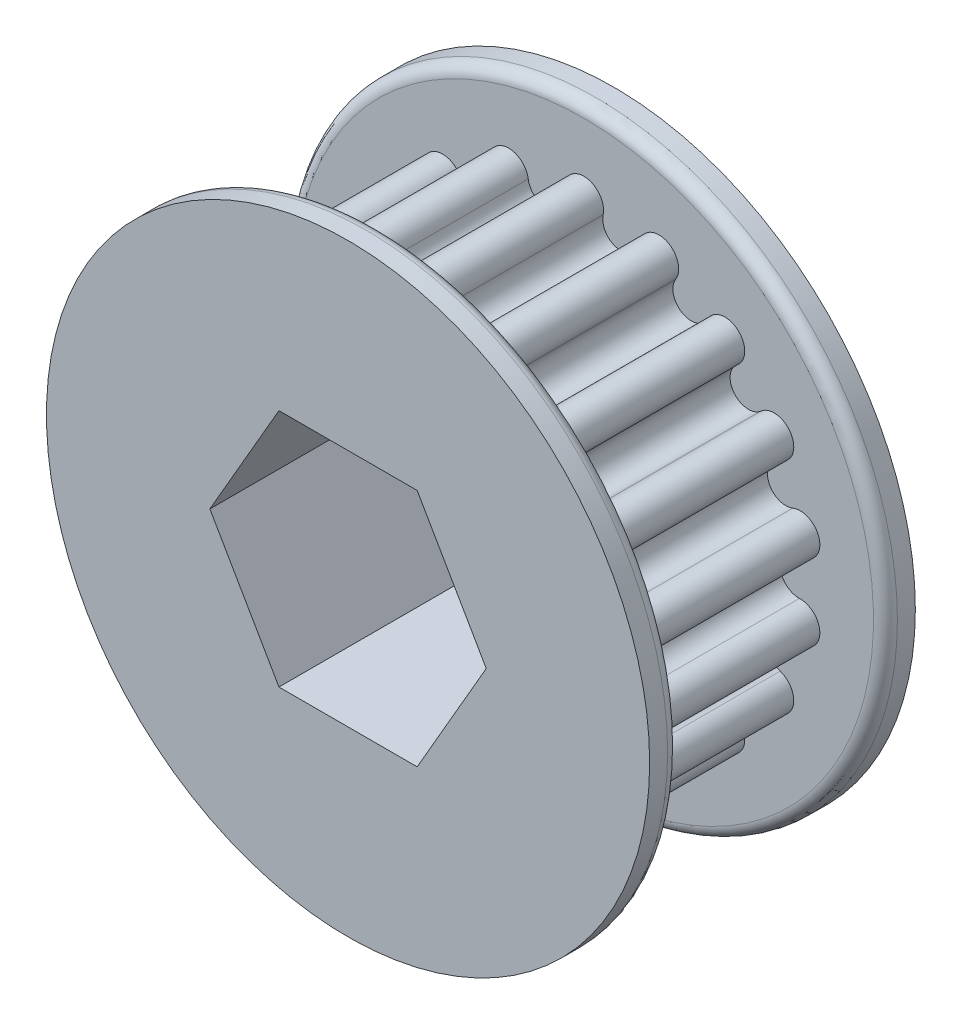
from build123d import *

# Parameters (mm, degrees)
BOSS_EXTRUDE1_DEPTH  = 10.922
SKETCH2_R            = 16.002
BOSS_EXTRUDE2_DEPTH  = 1.5875
FILLET1_R            = 0.635
FILLET1_OF_MIRROR1_R = 0.635


with BuildPart() as part:
    # Sketch1 → Boss-Extrude1 (new body)
    with BuildSketch(Plane.XY):
        with BuildLine():
            ThreePointArc((1.023014865, 11.438350063), (0, 12.7), (-1.023014865, 11.438350063))
            ThreePointArc((-1.023014865, 11.438350063), (-1.811146799, 10.271523911), (-2.950826609, 11.098424839))
            ThreePointArc((-2.950826609, 11.098424839), (-4.34365582, 11.934096284), (-4.873465647, 10.398641458))
            ThreePointArc((-4.873465647, 10.398641458), (-5.214989362, 9.032626536), (-6.568754843, 9.419865784))
            ThreePointArc((-6.568754843, 9.419865784), (-8.163402643, 9.728764428), (-8.136104548, 8.104703225))
            ThreePointArc((-8.136104548, 8.104703225), (-7.989827243, 6.704261093), (-9.3943943, 6.605131893))
            ThreePointArc((-9.3943943, 6.605131893), (-10.998522628, 6.35), (-10.417409164, 4.83321817))
            ThreePointArc((-10.417409164, 4.83321817), (-9.800974042, 3.567262818), (-11.086931157, 2.993721614))
            ThreePointArc((-11.086931157, 2.993721614), (-12.507058463, 2.205331856), (-11.442220491, 0.978775674))
            ThreePointArc((-11.442220491, 0.978775674), (-10.429978724, 0), (-11.442220491, -0.978775674))
            ThreePointArc((-11.442220491, -0.978775674), (-12.507058463, -2.205331856), (-11.086931157, -2.993721614))
            ThreePointArc((-11.086931157, -2.993721614), (-9.800974042, -3.567262818), (-10.417409164, -4.83321817))
            ThreePointArc((-10.417409164, -4.83321817), (-10.998522628, -6.35), (-9.3943943, -6.605131893))
            ThreePointArc((-9.3943943, -6.605131893), (-7.989827243, -6.704261093), (-8.136104548, -8.104703225))
            ThreePointArc((-8.136104548, -8.104703225), (-8.163402643, -9.728764428), (-6.568754843, -9.419865784))
            ThreePointArc((-6.568754843, -9.419865784), (-5.214989362, -9.032626536), (-4.873465647, -10.398641458))
            ThreePointArc((-4.873465647, -10.398641458), (-4.34365582, -11.934096284), (-2.950826609, -11.098424839))
            ThreePointArc((-2.950826609, -11.098424839), (-1.811146799, -10.271523911), (-1.023014865, -11.438350063))
            ThreePointArc((-1.023014865, -11.438350063), (0, -12.7), (1.023014865, -11.438350063))
            ThreePointArc((1.023014865, -11.438350063), (1.811146799, -10.271523911), (2.950826609, -11.098424839))
            ThreePointArc((2.950826609, -11.098424839), (4.34365582, -11.934096284), (4.873465647, -10.398641458))
            ThreePointArc((4.873465647, -10.398641458), (5.214989362, -9.032626536), (6.568754843, -9.419865784))
            ThreePointArc((6.568754843, -9.419865784), (8.163402643, -9.728764428), (8.136104548, -8.104703225))
            ThreePointArc((8.136104548, -8.104703225), (7.989827243, -6.704261093), (9.3943943, -6.605131893))
            ThreePointArc((9.3943943, -6.605131893), (10.998522628, -6.35), (10.417409164, -4.83321817))
            ThreePointArc((10.417409164, -4.83321817), (9.800974042, -3.567262818), (11.086931157, -2.993721614))
            ThreePointArc((11.086931157, -2.993721614), (12.507058463, -2.205331856), (11.442220491, -0.978775674))
            ThreePointArc((11.442220491, -0.978775674), (10.429978724, 0), (11.442220491, 0.978775674))
            ThreePointArc((11.442220491, 0.978775674), (12.507058463, 2.205331856), (11.086931157, 2.993721614))
            ThreePointArc((11.086931157, 2.993721614), (9.800974042, 3.567262818), (10.417409164, 4.83321817))
            ThreePointArc((10.417409164, 4.83321817), (10.998522628, 6.35), (9.3943943, 6.605131893))
            ThreePointArc((9.3943943, 6.605131893), (7.989827243, 6.704261093), (8.136104548, 8.104703225))
            ThreePointArc((8.136104548, 8.104703225), (8.163402643, 9.728764428), (6.568754843, 9.419865784))
            ThreePointArc((6.568754843, 9.419865784), (5.214989362, 9.032626536), (4.873465647, 10.398641458))
            ThreePointArc((4.873465647, 10.398641458), (4.34365582, 11.934096284), (2.950826609, 11.098424839))
            ThreePointArc((2.950826609, 11.098424839), (1.811146799, 10.271523911), (1.023014865, 11.438350063))
        make_face()
        Polygon((7.332348419, 0), (3.666174209, 6.35), (-3.666174209, 6.35), (-7.332348419, 0), (-3.666174209, -6.35), (3.666174209, -6.35), align=None, mode=Mode.SUBTRACT)
    extrude(amount=BOSS_EXTRUDE1_DEPTH)

    # Sketch2 → Boss-Extrude2 (add)
    with BuildSketch(Plane.XY.offset(10.922)):
        Circle(SKETCH2_R)
        Polygon((-3.666174209, 6.35), (-7.332348419, 0), (-3.666174209, -6.35), (3.666174209, -6.35), (7.332348419, 0), (3.666174209, 6.35), align=None, mode=Mode.SUBTRACT)
    boss_extrude2 = extrude(amount=BOSS_EXTRUDE2_DEPTH)

    # Fillet1
    fillet1_edges = [part.edges().sort_by_distance(p)[0] for p in [
        (-16.002, 0, 10.922),
    ]]
    fillet(fillet1_edges, radius=FILLET1_R)

    # Mirror1: Boss-Extrude2 across plane
    add(boss_extrude2.mirror(Plane.XY.offset(5.461)))

    # Fillet1 of Mirror1
    fillet1_of_mirror1_edges = [part.edges().sort_by_distance(p)[0] for p in [
        (-16.002, 0, 0),
    ]]
    fillet(fillet1_of_mirror1_edges, radius=FILLET1_OF_MIRROR1_R)


solid = part.part
